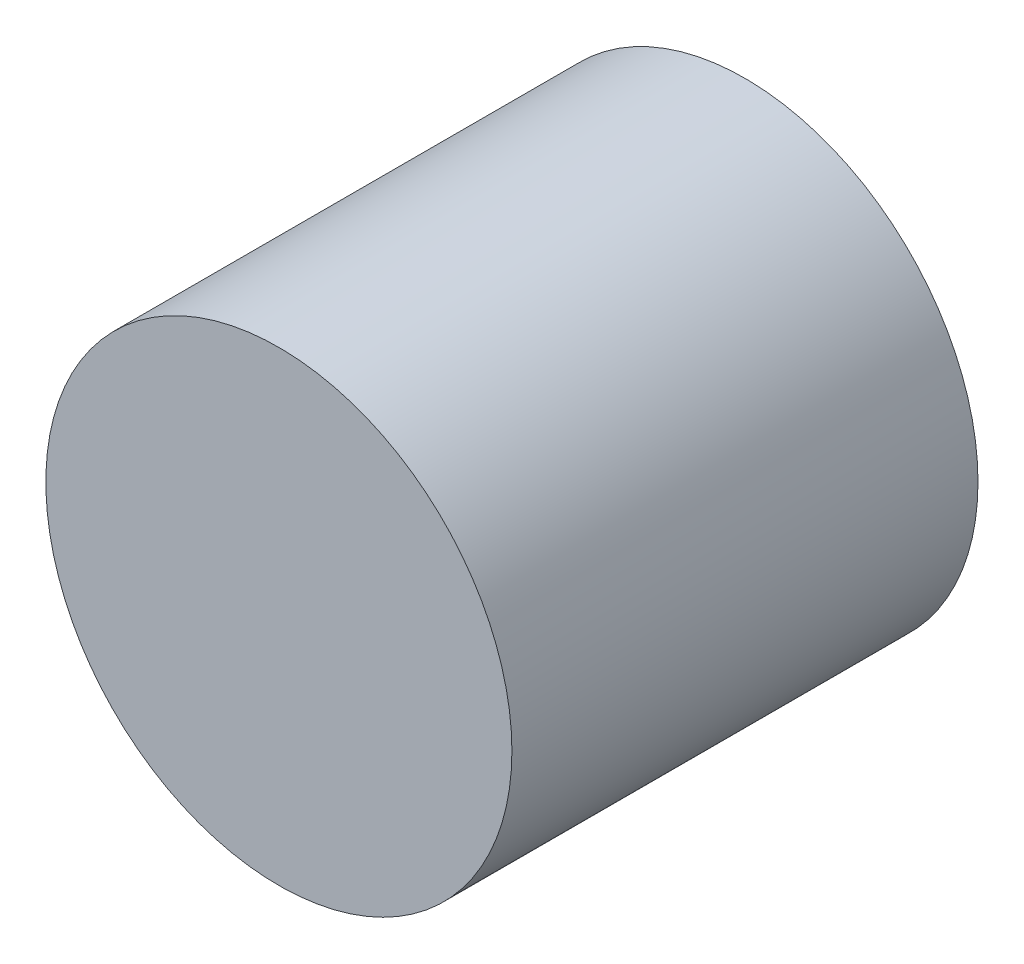
from build123d import *

# Parameters (mm, degrees)
SKETCH2_R           = 3
BOSS_EXTRUDE1_DEPTH = 6


with BuildPart() as part:
    # Sketch2 → Boss-Extrude1 (new body)
    with BuildSketch(Plane.XY):
        with Locations((-57.985351702, 22.209808612)):
            Circle(SKETCH2_R)
    extrude(amount=BOSS_EXTRUDE1_DEPTH)


solid = part.part
